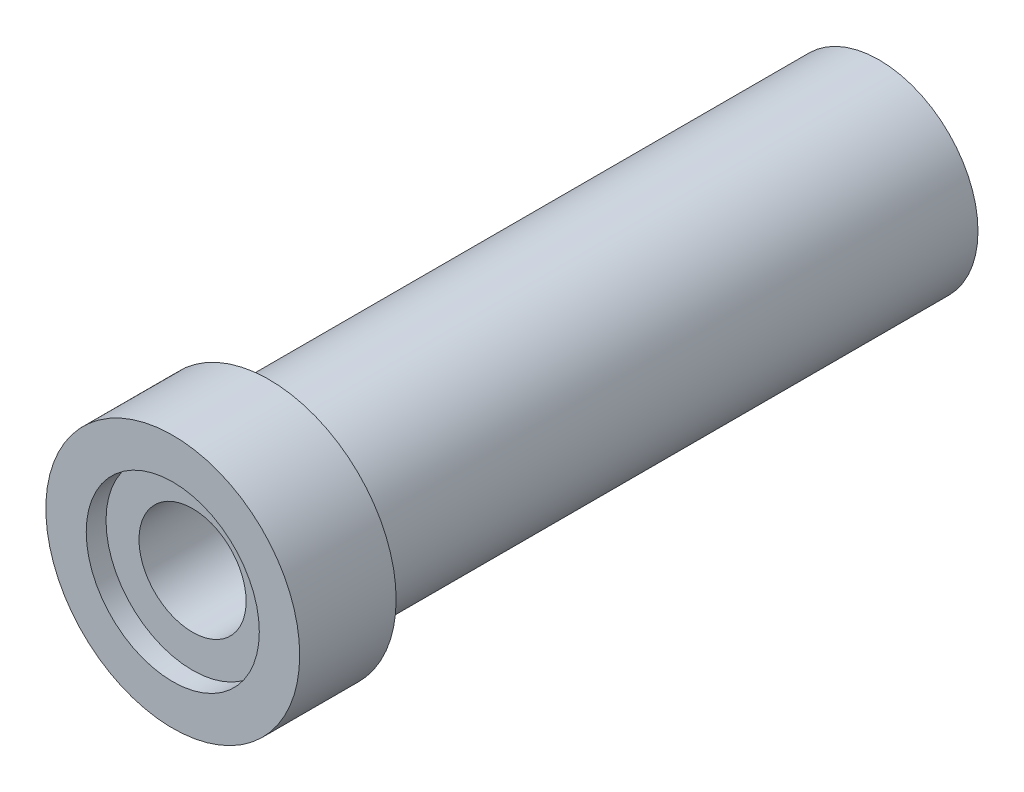
from build123d import *

# Parameters (mm, degrees)
SKETCH1_R           = 7.7
SKETCH1_R_2         = 3.25
BOSS_EXTRUDE1_DEPTH = 5.85
SKETCH2_R           = 5.25
CUT_EXTRUDE1_DEPTH  = 1.2
SKETCH4_R           = 6
SKETCH4_R_2         = 3.25
BOSS_EXTRUDE2_DEPTH = 7
SKETCH5_R           = 6
SKETCH5_R_2         = 4.6
BOSS_EXTRUDE5_DEPTH = 30


with BuildPart() as part:
    # Sketch1 → Boss-Extrude1 (new body)
    with BuildSketch(Plane.XY):
        Circle(SKETCH1_R)
        Circle(SKETCH1_R_2, mode=Mode.SUBTRACT)
    extrude(amount=BOSS_EXTRUDE1_DEPTH)

    # Sketch2 → Cut-Extrude1 (cut)
    with BuildSketch(Plane.XY.offset(5.85)):
        Circle(SKETCH2_R)
    extrude(amount=-CUT_EXTRUDE1_DEPTH, mode=Mode.SUBTRACT)

    # Sketch4 → Boss-Extrude2 (add)
    with BuildSketch(Plane(origin=(0, 0, 0), x_dir=(-1, 0, 0), z_dir=(0, 0, -1))):
        Circle(SKETCH4_R)
        Circle(SKETCH4_R_2, mode=Mode.SUBTRACT)
    extrude(amount=BOSS_EXTRUDE2_DEPTH)

    # Sketch5 → Boss-Extrude5 (add)
    with BuildSketch(Plane(origin=(0, 0, -7), x_dir=(-1, 0, 0), z_dir=(0, 0, -1))):
        Circle(SKETCH5_R)
        Circle(SKETCH5_R_2, mode=Mode.SUBTRACT)
    extrude(amount=BOSS_EXTRUDE5_DEPTH)


solid = part.part
